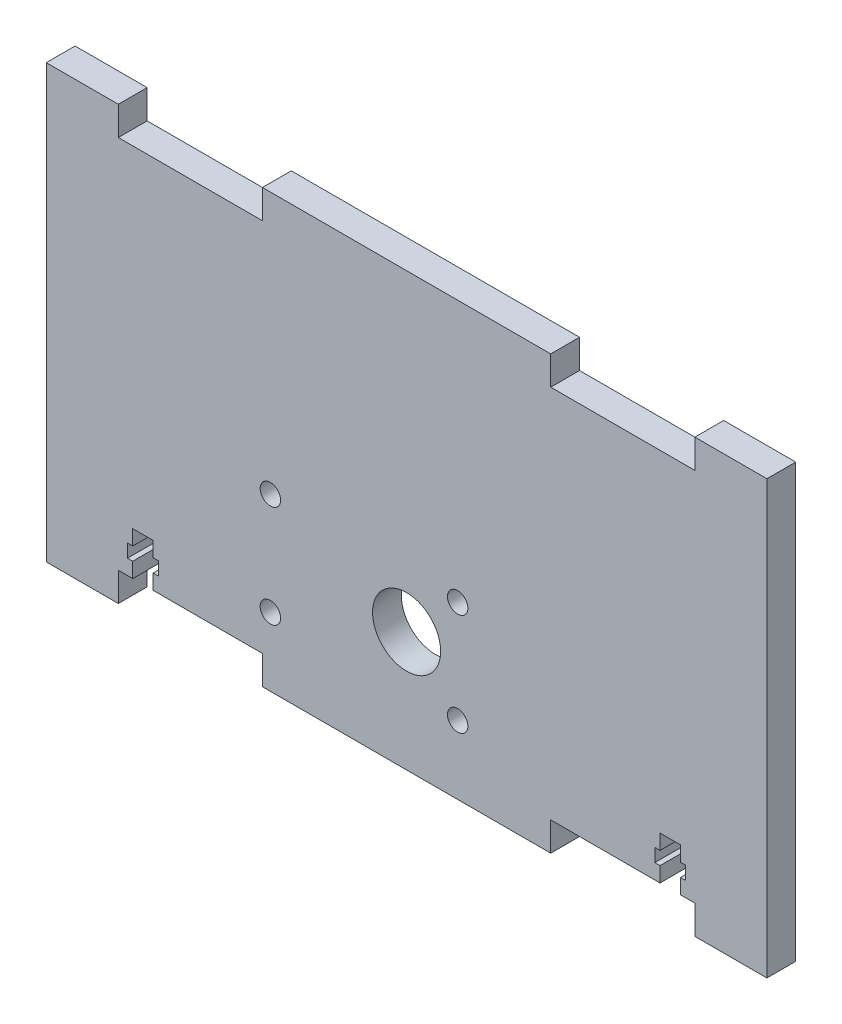
from build123d import *

# Parameters (mm, degrees)
SKETCH1_W                = 127
SKETCH1_H                = 76.2
BOSS_EXTRUDE1_DEPTH      = 5.08
CUT_EXTRUDE1_REACH       = 7.08
SKETCH2_W                = 25.4
SKETCH2_H                = 5.08
SKETCH3_W                = 25.4
SKETCH3_H                = 5.08
CUT_EXTRUDE2_DEPTH       = 6.08
CUT_EXTRUDE3_REACH       = 7.08
SKETCH4_R                = 6
SKETCH8_W                = 3.599999912
SKETCH8_H                = 7.62
CUT_EXTRUDE6_DEPTH       = 5.08
SKETCH9_W                = 5.4483
SKETCH9_H                = 2.3241
CUT_EXTRUDE7_DEPTH       = 5.08
M3_CLEARANCE_HOLE1_D     = 3.6
M3_CLEARANCE_HOLE1_DEPTH = 5.08


with BuildPart() as part:
    # Sketch1 → Boss-Extrude1 (new body)
    with BuildSketch(Plane.XY):
        with Locations((63.5, 38.1)):
            Rectangle(SKETCH1_W, SKETCH1_H)
    extrude(amount=BOSS_EXTRUDE1_DEPTH)

    # Sketch2 → Cut-Extrude1 (cut, up to next)
    with BuildSketch(Plane.XY.offset(5.08), mode=Mode.PRIVATE) as cut_extrude1_sk1:
        with Locations((25.4, 2.54)):
            Rectangle(SKETCH2_W, SKETCH2_H)
    cut_extrude1_tool1 = extrude(cut_extrude1_sk1.sketch, amount=-CUT_EXTRUDE1_REACH, mode=Mode.PRIVATE) & part.part
    add(cut_extrude1_tool1.solids().sort_by_distance((25.4, 2.54, 5.08))[0], mode=Mode.SUBTRACT)
    # Sketch2 → Cut-Extrude1 (cut, up to next)
    with BuildSketch(Plane.XY.offset(5.08), mode=Mode.PRIVATE) as cut_extrude1_sk2:
        with Locations((101.6, 2.54)):
            Rectangle(SKETCH2_W, SKETCH2_H)
    cut_extrude1_tool2 = extrude(cut_extrude1_sk2.sketch, amount=-CUT_EXTRUDE1_REACH, mode=Mode.PRIVATE) & part.part
    add(cut_extrude1_tool2.solids().sort_by_distance((101.6, 2.54, 5.08))[0], mode=Mode.SUBTRACT)

    # Sketch3 → Cut-Extrude2 (cut, through all)
    with BuildSketch(Plane.XY.offset(5.08)):
        with Locations((25.4, 73.66)):
            Rectangle(SKETCH3_W, SKETCH3_H)
        with Locations((101.6, 73.66)):
            Rectangle(SKETCH3_W, SKETCH3_H)
    extrude(amount=-CUT_EXTRUDE2_DEPTH, mode=Mode.SUBTRACT)

    # Sketch4 → Cut-Extrude3 (cut, up to next)
    with BuildSketch(Plane.XY.offset(5.08), mode=Mode.PRIVATE) as cut_extrude3_sk1:
        with Locations((63.5, 21.08)):
            Circle(SKETCH4_R)
    cut_extrude3_tool1 = extrude(cut_extrude3_sk1.sketch, amount=-CUT_EXTRUDE3_REACH, mode=Mode.PRIVATE) & part.part
    add(cut_extrude3_tool1.solids().sort_by_distance((63.5, 21.08, 5.08))[0], mode=Mode.SUBTRACT)

    # Sketch8 → Cut-Extrude6 (cut)
    with BuildSketch(Plane.XY.offset(5.08)):
        with Locations((17.039999956, 8.89)):
            Rectangle(SKETCH8_W, SKETCH8_H)
    cut_extrude6 = extrude(amount=-CUT_EXTRUDE6_DEPTH, mode=Mode.SUBTRACT)

    # Sketch9 → Cut-Extrude7 (cut)
    with BuildSketch(Plane.XY.offset(5.08)):
        with Locations((17.039999956, 8.89)):
            Rectangle(SKETCH9_W, SKETCH9_H)
    cut_extrude7 = extrude(amount=-CUT_EXTRUDE7_DEPTH, mode=Mode.SUBTRACT)

    # Mirror1: Cut-Extrude6, Cut-Extrude7 across plane
    add(cut_extrude6.mirror(Plane.ZY.offset(-63.5)), mode=Mode.SUBTRACT)
    add(cut_extrude7.mirror(Plane.ZY.offset(-63.5)), mode=Mode.SUBTRACT)

    # M3 Clearance Hole1
    with Locations(Plane.XY.offset(5.08)):
        with Locations((39.5, 30.08), (72.5, 30.08), (72.5, 12.08), (39.5, 12.08)):
            Hole(M3_CLEARANCE_HOLE1_D / 2, depth=M3_CLEARANCE_HOLE1_DEPTH)


solid = part.part
